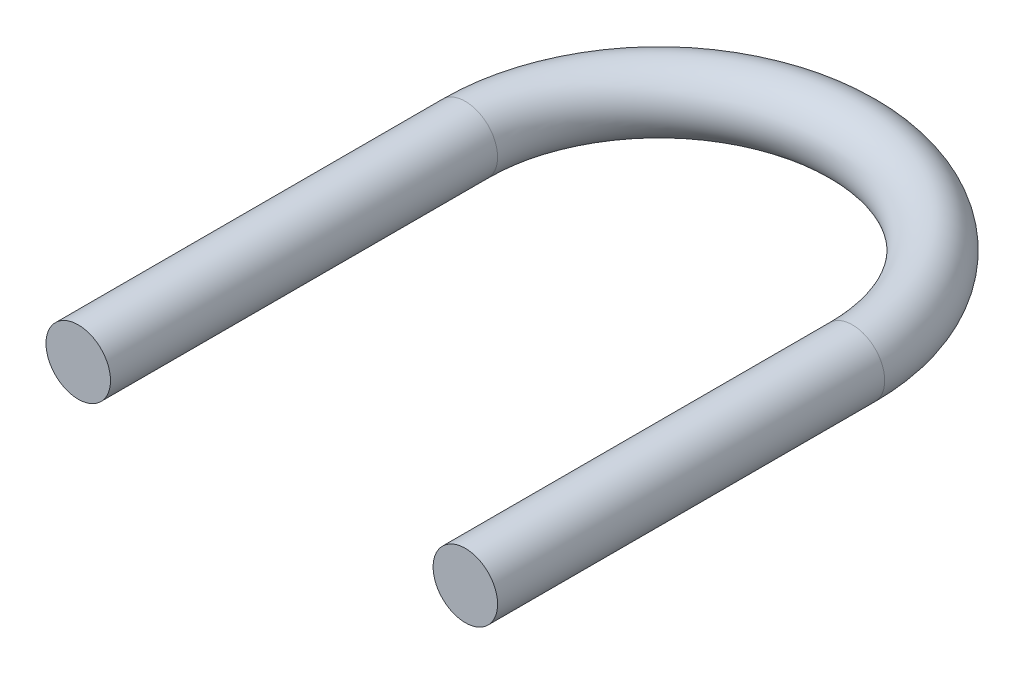
from build123d import *

# Parameters (mm, degrees)
SKETCH4_R = 25.4
SKETCH7_R = 25.4


with BuildPart() as part:
    # Sweep1: sweep along a path in Sketch3
    with BuildLine(Plane(origin=(0, 1676.4, 0), x_dir=(1, 0, 0), z_dir=(0, 1, 0))) as sweep1_path:
        Line((330.2, 419.1), (330.2, 723.9))
    # Sketch4 → Sweep1 (sweep)
    with BuildSketch(Plane.XY.offset(-419.1)):
        with Locations((330.2, 1676.4)):
            Circle(SKETCH4_R)
    sweep(path=sweep1_path.line)

    # Sweep2: sweep along a curve in space
    with BuildLine() as sweep2_path:
        Line((25.4, 1676.4, -419.1), (25.4, 1676.4, -723.9))
        ThreePointArc((25.4, 1676.4, -723.9), (177.8, 1676.4, -876.3), (330.2, 1676.4, -723.9))
    # Sketch7 → Sweep2 (sweep)
    with BuildSketch(Plane.XY.offset(-419.1)):
        with Locations((25.4, 1676.4)):
            Circle(SKETCH7_R)
    sweep(path=sweep2_path.line)


solid = part.part
